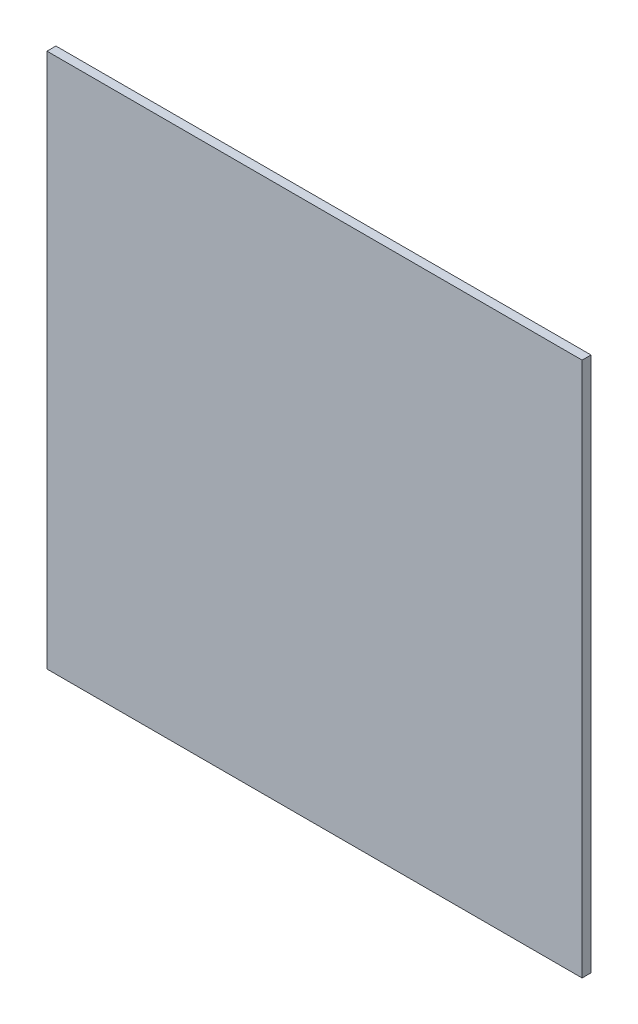
from build123d import *

# Parameters (mm, degrees)
SKETCH_1_W      = 180
SKETCH_1_H      = 180
EXTRUDE_1_DEPTH = 3


with BuildPart() as part:
    # 草图1 → 凸台-拉伸1 (new body)
    with BuildSketch(Plane.XY):
        with Locations((90, 90)):
            Rectangle(SKETCH_1_W, SKETCH_1_H)
    extrude(amount=EXTRUDE_1_DEPTH)


solid = part.part
